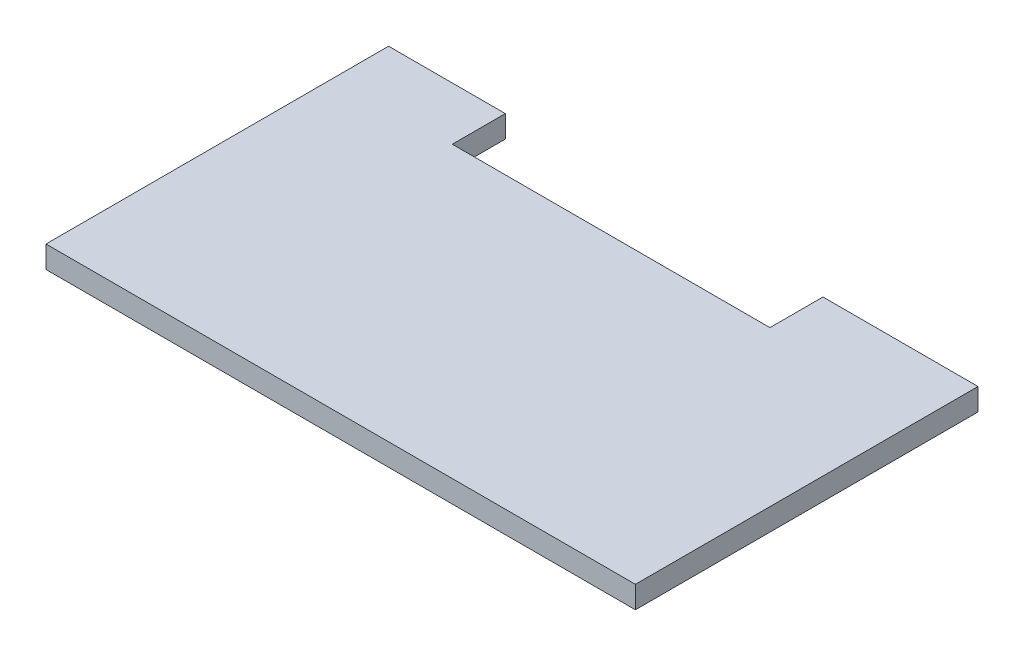
from build123d import *

# Parameters (mm, degrees)
BOSS_EXTRUDE1_DEPTH = 3


with BuildPart() as part:
    # Sketch1 → Boss-Extrude1 (new body)
    with BuildSketch(Plane(origin=(0, 0, 0), x_dir=(1, 0, 0), z_dir=(0, 1, 0))):
        Polygon((15.843156539, 46.5), (15.843156539, 39.3), (58.956843461, 39.3), (58.956843461, 46.5), (80, 46.5), (80, 0), (0, 0), (0, 46.5), align=None)
    extrude(amount=-BOSS_EXTRUDE1_DEPTH)


solid = part.part
